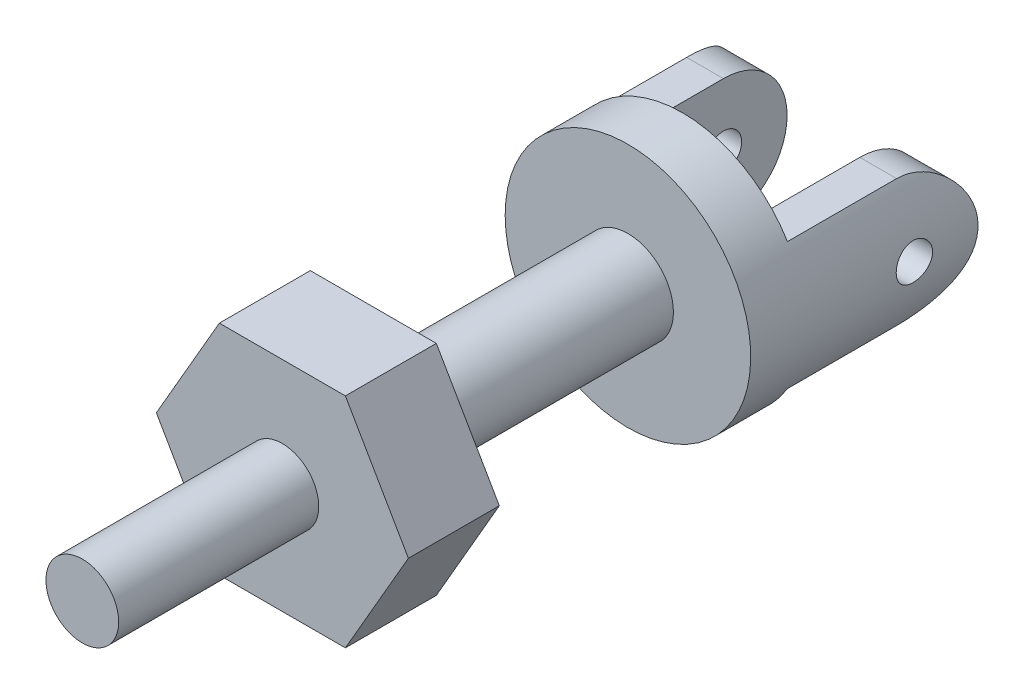
from build123d import *

# Parameters (mm, degrees)
HEXAGON_DEPTH            = 5
SKETCH3_R                = 2
SCREW_POST_DEPTH         = 11
SKETCH4_R                = 2.5
BEARING_SECTION_DEPTH    = 14
SKETCH5_R                = 6.75
U_JOINT_BASE_DEPTH       = 3
U_JOINT_STANDUPS_DEPTH   = 9.5
STANDUP_ROUND_DEPTH      = 7.928203
STANDUP_ROUND_DEPTH_BACK = 7.928203
SKETCH8_R                = 1
BALL_HOLES_DEPTH         = 7.928203
BALL_HOLES_DEPTH_BACK    = 7.928203


with BuildPart() as part:
    # Sketch2 → Hexagon (new body)
    with BuildSketch(Plane.XY):
        Polygon((3.464102, -6), (6.928203, 0), (3.464102, 6), (-3.464102, 6), (-6.928203, 0), (-3.464102, -6), align=None)
    extrude(amount=HEXAGON_DEPTH)

    # Sketch3 → Screw Post (add)
    with BuildSketch(Plane.XY.offset(5)):
        Circle(SKETCH3_R)
    extrude(amount=SCREW_POST_DEPTH)

    # Sketch4 → Bearing Section (add)
    with BuildSketch(Plane(origin=(0, 0, 0), x_dir=(-1, 0, 0), z_dir=(0, 0, -1))):
        Circle(SKETCH4_R)
    extrude(amount=BEARING_SECTION_DEPTH)

    # Sketch5 → U Joint Base (add)
    with BuildSketch(Plane(origin=(0, 0, -14), x_dir=(-1, 0, 0), z_dir=(0, 0, -1))):
        Circle(SKETCH5_R)
    extrude(amount=U_JOINT_BASE_DEPTH)

    # Sketch6 → U Joint Standups (add)
    with BuildSketch(Plane(origin=(0, 0, -17), x_dir=(-1, 0, 0), z_dir=(0, 0, -1))):
        with BuildLine():
            Line((-5.771698, 3.5), (-3.75, 3.5))
            Line((-3.75, 3.5), (-3.75, -3.5))
            Line((-3.75, -3.5), (-5.771698, -3.5))
            ThreePointArc((-5.771698, -3.5), (-6.75, 0), (-5.771698, 3.5))
        make_face()
        with BuildLine():
            Line((3.75, -3.5), (3.75, 3.5))
            Line((3.75, 3.5), (5.771698, 3.5))
            ThreePointArc((5.771698, 3.5), (6.75, 0), (5.771698, -3.5))
            Line((5.771698, -3.5), (3.75, -3.5))
        make_face()
    extrude(amount=U_JOINT_STANDUPS_DEPTH)

    # Sketch7 → Standup Round (cut, two sides)
    with BuildSketch(Plane(origin=(0, 0, 0), x_dir=(0, 0, -1), z_dir=(1, 0, 0))) as standup_round_sk:
        with BuildLine():
            Line((26.5, -3.5), (26.5, 0))
            ThreePointArc((26.5, 0), (25.474874, -2.474874), (23, -3.5))
            Line((23, -3.5), (26.5, -3.5))
        make_face()
        with BuildLine():
            Line((26.5, 3.5), (23, 3.5))
            ThreePointArc((23, 3.5), (25.474874, 2.474874), (26.5, 0))
            Line((26.5, 0), (26.5, 3.5))
        make_face()
    extrude(amount=STANDUP_ROUND_DEPTH, mode=Mode.SUBTRACT)
    extrude(standup_round_sk.sketch, amount=-STANDUP_ROUND_DEPTH_BACK, mode=Mode.SUBTRACT)

    # Sketch8 → Ball Holes (cut, two sides)
    with BuildSketch(Plane(origin=(0, 0, 0), x_dir=(0, 0, -1), z_dir=(1, 0, 0))) as ball_holes_sk:
        with Locations((23, 0)):
            Circle(SKETCH8_R)
    extrude(amount=BALL_HOLES_DEPTH, mode=Mode.SUBTRACT)
    extrude(ball_holes_sk.sketch, amount=-BALL_HOLES_DEPTH_BACK, mode=Mode.SUBTRACT)


solid = part.part
